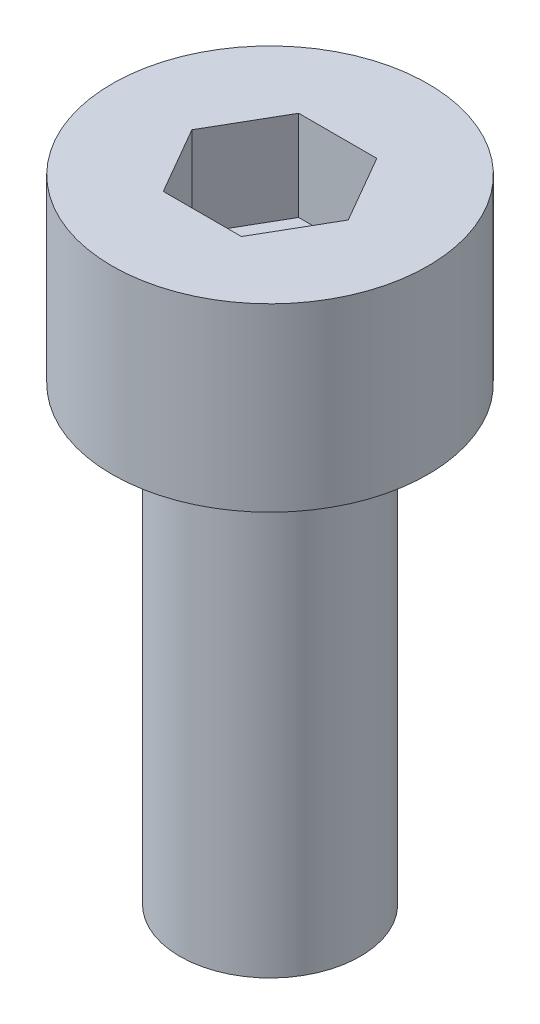
from build123d import *

# Parameters (mm, degrees)
SKETCH_1_R            = 3.5
EXTRUDE_246_DEPTH     = 4
CUT_EXTRUDE_376_DEPTH = 2
SKETCH_3_R            = 2
EXTRUDE_477_DEPTH     = 10


with BuildPart() as part:
    # 草图1 → Extrude 246 (new body)
    with BuildSketch(Plane(origin=(0, 0, 0), x_dir=(1, 0, 0), z_dir=(0, 1, 0))):
        Circle(SKETCH_1_R)
    extrude(amount=EXTRUDE_246_DEPTH)

    # 草图2 → Cut-Extrude 376 (cut)
    with BuildSketch(Plane(origin=(0, 4, 0), x_dir=(1, 0, 0), z_dir=(0, 1, 0))):
        Polygon((1.732050808, 0), (0.866025404, 1.5), (-0.866025404, 1.5), (-1.732050808, 0), (-0.866025404, -1.5), (0.866025404, -1.5), align=None)
    extrude(amount=-CUT_EXTRUDE_376_DEPTH, mode=Mode.SUBTRACT)

    # 草图3 → Extrude 477 (add)
    with BuildSketch(Plane.XZ):
        Circle(SKETCH_3_R)
    extrude(amount=EXTRUDE_477_DEPTH)


solid = part.part
